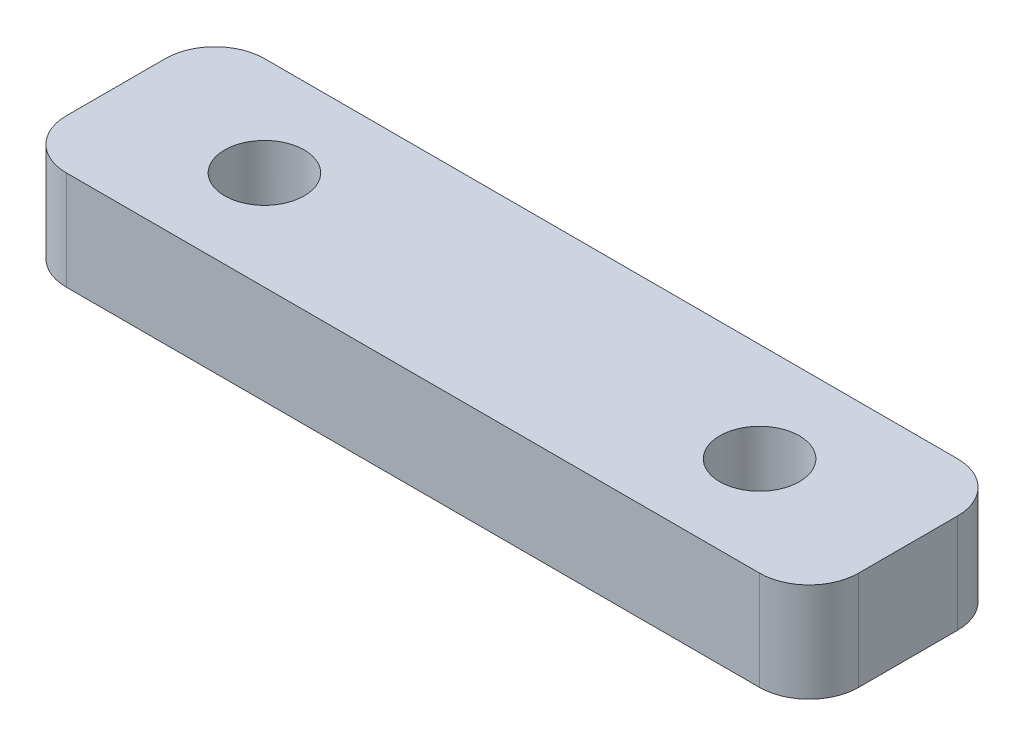
from build123d import *

# Parameters (mm, degrees)
SKETCH1_W                       = 50.8
SKETCH1_H                       = 12.7
BOSS_EXTRUDE1_DEPTH             = 6.35
TAP_DRILL_FOR_1_4_20_TAP1_D     = 5.1054
TAP_DRILL_FOR_1_4_20_TAP1_DEPTH = 6.35
FILLET1_R                       = 3.175


with BuildPart() as part:
    # Sketch1 → Boss-Extrude1 (new body)
    with BuildSketch(Plane(origin=(0, 0, 0), x_dir=(1, 0, 0), z_dir=(0, 1, 0))):
        with Locations((25.4, -6.35)):
            Rectangle(SKETCH1_W, SKETCH1_H)
    extrude(amount=BOSS_EXTRUDE1_DEPTH)

    # Tap Drill for 1/4-20 Tap1
    with Locations(Plane(origin=(0, 0, 0), x_dir=(-1, 0, 0), z_dir=(0, -1, 0))):
        with Locations((-9.525, -6.35), (-41.275, -6.35)):
            Hole(TAP_DRILL_FOR_1_4_20_TAP1_D / 2, depth=TAP_DRILL_FOR_1_4_20_TAP1_DEPTH)

    # Fillet1
    fillet1_edges = [part.edges().sort_by_distance(p)[0] for p in [
        (0, 3.175, 0),
        (50.8, 3.175, 0),
        (50.8, 3.175, 12.7),
        (0, 3.175, 12.7),
    ]]
    fillet(fillet1_edges, radius=FILLET1_R)


solid = part.part
